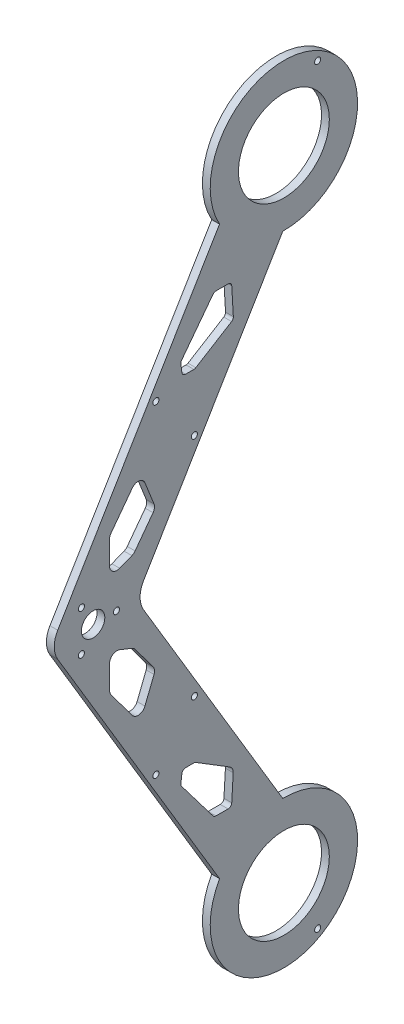
from build123d import *

# Parameters (mm, degrees)
EXTRUDE_BASE_DEPTH         = 3.18
SKETCH4_R                  = 18.5
CUT_MOTOR_HOLES_DEPTH      = 3.18
SKETCH6_R                  = 1.25
SKETCH6_R_2                = 4.765
SUPPORT_HOLES_DEPTH        = 3.18
CUT_LIGHTENING_HOLES_DEPTH = 3.18


with BuildPart() as part:
    # bogie base → extrude-base (new body)
    with BuildSketch(Plane.YZ):
        with BuildLine():
            Line((124.870587973, 92.088866631), (14.608385018, 26.202959511))
            ThreePointArc((14.608385018, 26.202959511), (-25.75271229, -15.388236082), (29.9966211, 0.450247222))
            Line((29.9966211, 0.450247222), (124.870587973, 57.141091426))
            ThreePointArc((124.870587973, 57.141091426), (130, 58.556853997), (135.129412027, 57.141091426))
            Line((135.129412027, 57.141091426), (230.0033789, 0.450247222))
            ThreePointArc((230.0033789, 0.450247222), (285.75271229, -15.388236082), (245.391614982, 26.202959511))
            Line((245.391614982, 26.202959511), (135.129412027, 92.088866631))
            ThreePointArc((135.129412027, 92.088866631), (130, 93.504629201), (124.870587973, 92.088866631))
        make_face()
    extrude(amount=EXTRUDE_BASE_DEPTH)

    # Sketch4 → Cut-motor holes (cut)
    with BuildSketch(Plane.YZ):
        with Locations((260, 0)):
            Circle(SKETCH4_R)
        Circle(SKETCH4_R)
    extrude(amount=CUT_MOTOR_HOLES_DEPTH, mode=Mode.SUBTRACT)

    # Sketch6 → support holes (cut)
    with BuildSketch(Plane.YZ):
        with Locations((64.164835578, 52.110380567)):
            Circle(SKETCH6_R)
        with Locations((84.016579298, 36.433714107)):
            Circle(SKETCH6_R)
        with Locations((130, 77.68)):
            Circle(SKETCH6_R_2)
        with Locations((130, 68.17)):
            Circle(SKETCH6_R)
        with Locations((121.77231361, 82.449200841)):
            Circle(SKETCH6_R)
        with Locations((138.248750332, 82.43704307)):
            Circle(SKETCH6_R)
        with Locations((175.983420702, 36.433714107)):
            Circle(SKETCH6_R)
        with Locations((195.835164422, 52.110380567)):
            Circle(SKETCH6_R)
        with Locations((-23.022924787, -13.757083057)):
            Circle(SKETCH6_R)
        with Locations((283.022924787, -13.757083057)):
            Circle(SKETCH6_R)
    extrude(amount=SUPPORT_HOLES_DEPTH, mode=Mode.SUBTRACT)

    # Sketch7 → Cut-lightening holes (cut)
    with BuildSketch(Plane.YZ):
        with BuildLine():
            Line((54.884000108, 41.646401467), (38.03439682, 28.860792879))
            ThreePointArc((38.03439682, 28.860792879), (37.597600164, 28.332915929), (37.441118366, 27.665863577))
            Line((37.441118366, 27.665863577), (37.441118366, 22.734591544))
            ThreePointArc((37.441118366, 22.734591544), (37.849837551, 21.705462697), (38.853259944, 21.237166789))
            Line((38.853259944, 21.237166789), (49.165938422, 20.63209087))
            ThreePointArc((49.165938422, 20.63209087), (50.727348318, 20.966140733), (51.896208282, 22.053962665))
            Line((51.896208282, 22.053962665), (60.398420976, 35.861757183))
            ThreePointArc((60.398420976, 35.861757183), (60.564389902, 36.239537563), (60.621144468, 36.64824604))
            Line((60.621144468, 36.64824604), (60.621144468, 40.036157787))
            ThreePointArc((60.621144468, 40.036157787), (60.245516663, 41.02902594), (59.306761578, 41.524628912))
            Line((59.306761578, 41.524628912), (55.976338764, 41.939943289))
            ThreePointArc((55.976338764, 41.939943289), (55.401440776, 41.900078528), (54.884000108, 41.646401467))
        make_face()
        with BuildLine():
            Line((200.693238422, 41.524628912), (204.023661236, 41.939943289))
            ThreePointArc((204.023661236, 41.939943289), (204.598559224, 41.900078528), (205.115999892, 41.646401467))
            Line((205.115999892, 41.646401467), (221.96560318, 28.860792879))
            ThreePointArc((221.96560318, 28.860792879), (222.402399836, 28.332915929), (222.558881634, 27.665863577))
            Line((222.558881634, 27.665863577), (222.558881634, 22.734591544))
            ThreePointArc((222.558881634, 22.734591544), (222.150162449, 21.705462697), (221.146740056, 21.237166789))
            Line((221.146740056, 21.237166789), (209.939024731, 20.579576362))
            ThreePointArc((209.939024731, 20.579576362), (209.158319783, 20.746601293), (208.573889801, 21.290512259))
            Line((208.573889801, 21.290512259), (199.601579024, 35.861757183))
            ThreePointArc((199.601579024, 35.861757183), (199.435610098, 36.239537563), (199.378855532, 36.64824604))
            Line((199.378855532, 36.64824604), (199.378855532, 40.036157787))
            ThreePointArc((199.378855532, 40.036157787), (199.754483337, 41.02902594), (200.693238422, 41.524628912))
        make_face()
        with BuildLine():
            Line((112.843083605, 70.967653341), (103.290433505, 70.967653341))
            ThreePointArc((103.290433505, 70.967653341), (102.345892271, 70.815080576), (101.497425215, 70.372881245))
            Line((101.497425215, 70.372881245), (89.954993447, 61.768426002))
            ThreePointArc((89.954993447, 61.768426002), (88.773863738, 58.970129198), (90.641401413, 56.574751268))
            Line((90.641401413, 56.574751268), (99.94028895, 52.884470408))
            ThreePointArc((99.94028895, 52.884470408), (101.439958174, 52.698779238), (102.839897564, 53.267689334))
            Line((102.839897564, 53.267689334), (112.662933935, 60.59039901))
            ThreePointArc((112.662933935, 60.59039901), (113.250900477, 61.170535451), (113.658372475, 61.88902659))
            Line((113.658372475, 61.88902659), (115.631530434, 66.861053016))
            ThreePointArc((115.631530434, 66.861053016), (115.324998286, 69.65291282), (112.843083605, 70.967653341))
        make_face()
        with BuildLine():
            Line((146.341627525, 61.88902659), (144.368469566, 66.861053016))
            ThreePointArc((144.368469566, 66.861053016), (144.675001714, 69.65291282), (147.156916395, 70.967653341))
            Line((147.156916395, 70.967653341), (156.709566495, 70.967653341))
            ThreePointArc((156.709566495, 70.967653341), (157.654107729, 70.815080576), (158.502574785, 70.372881245))
            Line((158.502574785, 70.372881245), (170.045006553, 61.768426002))
            ThreePointArc((170.045006553, 61.768426002), (171.226136262, 58.970129198), (169.358598587, 56.574751268))
            Line((169.358598587, 56.574751268), (160.05971105, 52.884470408))
            ThreePointArc((160.05971105, 52.884470408), (158.560041826, 52.698779238), (157.160102436, 53.267689334))
            Line((157.160102436, 53.267689334), (147.337066065, 60.59039901))
            ThreePointArc((147.337066065, 60.59039901), (146.749099523, 61.170535451), (146.341627525, 61.88902659))
        make_face()
    extrude(amount=CUT_LIGHTENING_HOLES_DEPTH, mode=Mode.SUBTRACT)


solid = part.part
